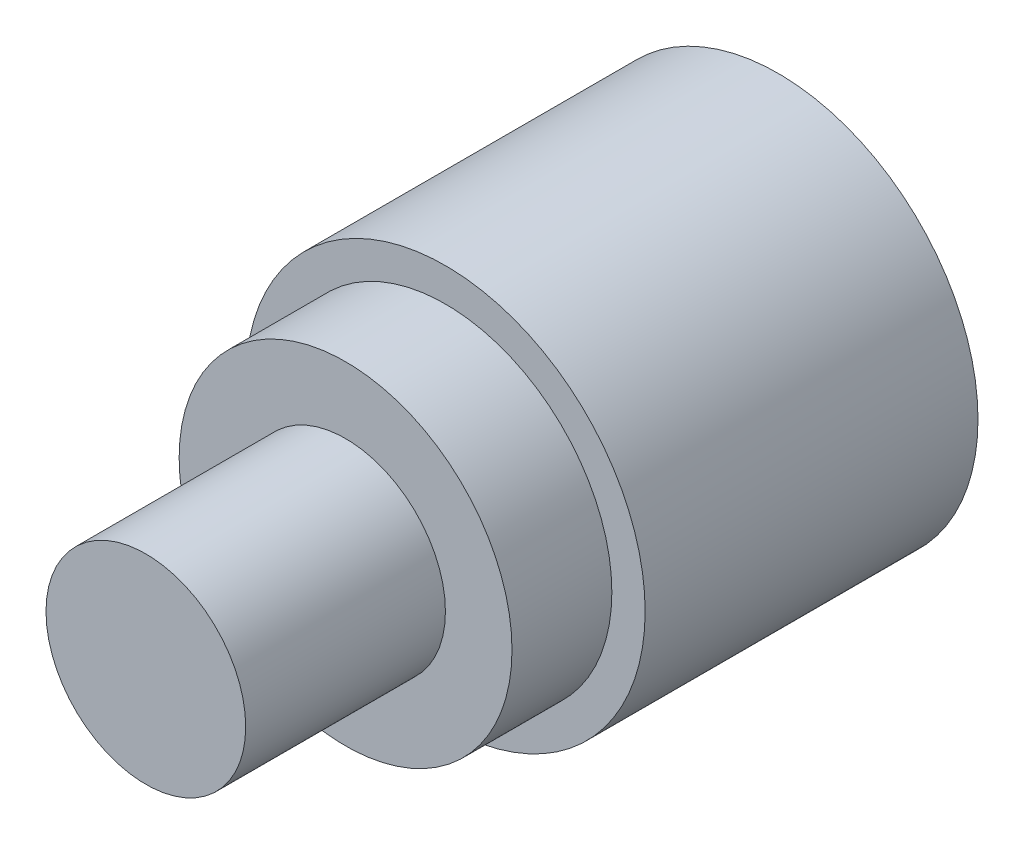
from build123d import *

# Parameters (mm, degrees)
SKETCH_1_R      = 30
EXTRUDE_1_DEPTH = 25
SKETCH_3_R      = 25
EXTRUDE_2_DEPTH = 15
SKETCH_4_R      = 15
EXTRUDE_3_DEPTH = 30


with BuildPart() as part:
    # 草图1 → 凸台-拉伸1 (new body, symmetric)
    with BuildSketch(Plane.XY):
        Circle(SKETCH_1_R)
    extrude(amount=EXTRUDE_1_DEPTH, both=True)

    # 草图3 → 凸台-拉伸2 (add)
    with BuildSketch(Plane.XY.offset(25)):
        Circle(SKETCH_3_R)
    extrude(amount=EXTRUDE_2_DEPTH)

    # 草图4 → 凸台-拉伸3 (add)
    with BuildSketch(Plane.XY.offset(40)):
        Circle(SKETCH_4_R)
    extrude(amount=EXTRUDE_3_DEPTH)


solid = part.part
